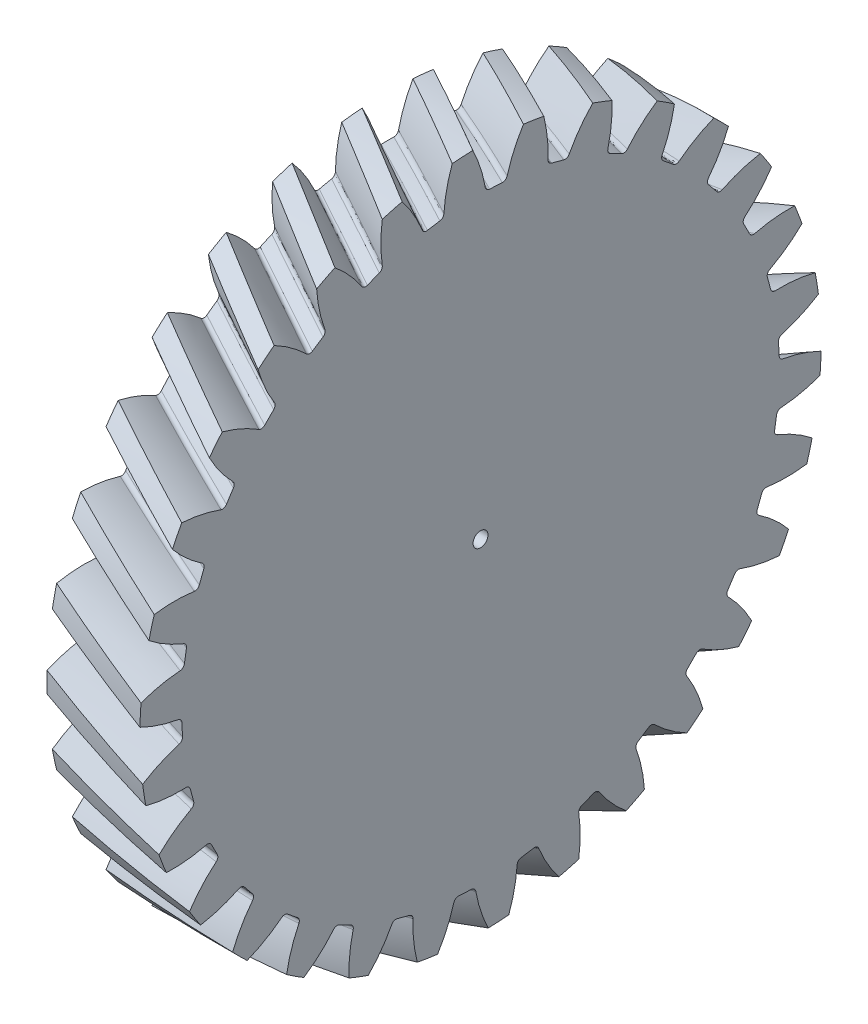
from build123d import *

# Parameters (mm, degrees)
BASPROSKE_W            = 5
BASPROSKE_H            = 18.320508076
TOOTHCUTRH_PITCH       = 199.378355401
TOOTHCUTRH_HEIGHT      = 5
TOOTHCUTRH_RADIUS      = 18.320508076
TOOTHCUTRH_START_ANGLE = -90
TEETHCUTSRH_COUNT      = 30
TEETHCUTSRH_ANGLE      = 348
BORSKE_R               = 0.4
BORE_DEPTH             = 62.5000025


with BuildPart() as part:
    # BasProSke → Base-Revolve (revolve)
    with BuildSketch(Plane(origin=(0, 0, 0), x_dir=(1, 0, 0), z_dir=(0, 1, 0))):
        with Locations((2.5, 9.160254038)):
            Rectangle(BASPROSKE_W, BASPROSKE_H)
    revolve(axis=Axis((-10, 0, 0), (1, 0, 0)))

    # ToothCutRH: sweep along a helix
    with BuildLine() as toothcutrh_path:
        add(Helix(TOOTHCUTRH_PITCH, TOOTHCUTRH_HEIGHT, TOOTHCUTRH_RADIUS, center=(0, 0, 0), direction=(1, 0, 0), mode=Mode.PRIVATE).rotate(Axis((0, 0, 0), (1, 0, 0)), TOOTHCUTRH_START_ANGLE))
    # TooCutSkeRH → ToothCutRH (sweep, cut)
    with BuildSketch(Plane(origin=(0, 0, 0), x_dir=(0, 0, -1), z_dir=(1, 0, 0))):
        with BuildLine():
            ThreePointArc((0.339990932, 16.066911215), (0, 16.070508076), (-0.339990932, 16.066911215))
            ThreePointArc((-0.339990932, 16.066911215), (-0.499727416, 16.11998254), (-0.59001654, 16.262039515))
            ThreePointArc((-0.59001654, 16.262039515), (-1.021822674, 17.579207163), (-1.68864971, 18.794414495))
            ThreePointArc((-1.68864971, 18.794414495), (0, 18.870123318), (1.68864971, 18.794414495))
            ThreePointArc((1.68864971, 18.794414495), (1.021822674, 17.579207163), (0.59001654, 16.262039515))
            ThreePointArc((0.59001654, 16.262039515), (0.499727416, 16.11998254), (0.339990932, 16.066911215))
        make_face()
    toothcutrh = sweep(path=toothcutrh_path.line, is_frenet=True, mode=Mode.SUBTRACT)

    # TeethCutsRH: ToothCutRH ×30 about axis
    teethcutsrh_axis = Axis((-10, 0, 0), (1, 0, 0))
    for i in range(1, TEETHCUTSRH_COUNT):
        add(toothcutrh.rotate(teethcutsrh_axis, i * TEETHCUTSRH_ANGLE / (TEETHCUTSRH_COUNT - 1)), mode=Mode.SUBTRACT)

    # BorSke → Bore (cut, symmetric)
    with BuildSketch(Plane(origin=(0, 0, 0), x_dir=(0, 0, -1), z_dir=(1, 0, 0))):
        Circle(BORSKE_R)
    extrude(amount=BORE_DEPTH, both=True, mode=Mode.SUBTRACT)


solid = part.part
